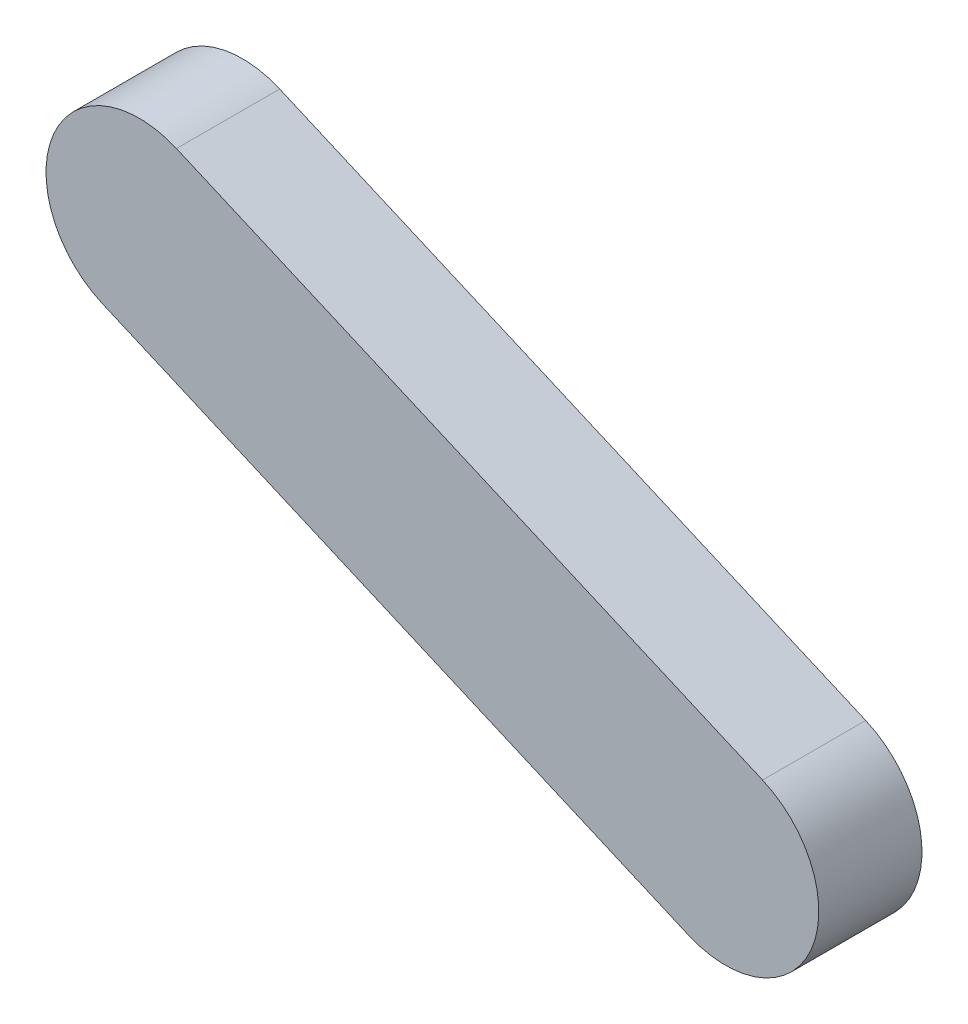
from build123d import *

# Parameters (mm, degrees)
BOSS_EXTRUDE1_DEPTH = 53.34


with BuildPart() as part:
    # Sketch1 → Boss-Extrude1 (new body)
    with BuildSketch(Plane.XY):
        with BuildLine():
            Line((-1275.557065722, 636.143536296), (-972.557861111, 504.905119645))
            ThreePointArc((-972.557861111, 504.905119645), (-947.454361332, 441.439621153), (-1010.919859824, 416.336121374))
            Line((-1010.919859824, 416.336121374), (-1313.919064435, 547.574538025))
            ThreePointArc((-1313.919064435, 547.574538025), (-1339.022564214, 611.040036517), (-1275.557065722, 636.143536296))
        make_face()
    extrude(amount=BOSS_EXTRUDE1_DEPTH)


solid = part.part
